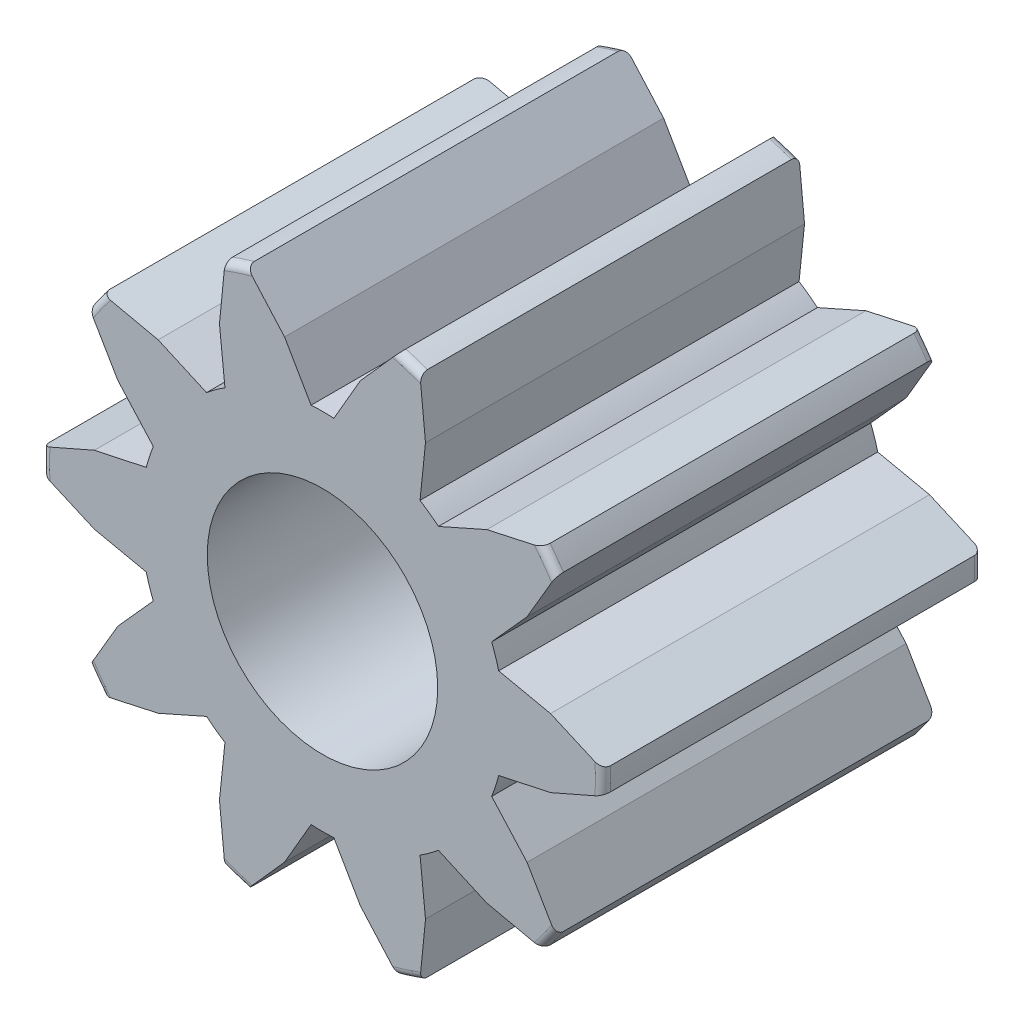
from build123d import *

# Parameters (mm, degrees)
CROQUIS1_R              = 1.85
SALIENTE_EXTRUIR1_DEPTH = 2.5
CORTAR_EXTRUIR1_DEPTH   = 2.85
REDONDEO1_R             = 0.05
MATRIZC1_COUNT          = 10
CROQUIS2_3_R            = 0.76
CORTAR_EXTRUIR2_DEPTH   = 2.85


with BuildPart() as part:
    # Croquis1 → Saliente-Extruir1 (new body)
    with BuildSketch(Plane.XY):
        Circle(CROQUIS1_R)
    extrude(amount=SALIENTE_EXTRUIR1_DEPTH)

    # Croquis2 → Cortar-Extruir1 (cut)
    with BuildSketch(Plane.XY.offset(2.5)):
        with BuildLine():
            Line((0.5, 1.781151313), (0.5, 2.25))
            Line((0.5, 2.25), (-0.5, 2.25))
            Line((-0.5, 2.25), (-0.5, 1.781151313))
            Line((-0.5, 1.781151313), (-0.25, 1.5))
            Line((-0.25, 1.5), (-0.075, 1.197653957))
            ThreePointArc((-0.075, 1.197653957), (0, 1.2), (0.075, 1.197653957))
            Line((0.075, 1.197653957), (0.25, 1.5))
            Line((0.25, 1.5), (0.5, 1.781151313))
        make_face()
    cortar_extruir1 = extrude(amount=-CORTAR_EXTRUIR1_DEPTH, mode=Mode.SUBTRACT)

    # Redondeo1
    redondeo1_edges = [part.edges().sort_by_distance(p)[0] for p in [
        (0, -1.85, 0),
        (0, -1.85, 2.5),
    ]]
    fillet(redondeo1_edges, radius=REDONDEO1_R)

    # MatrizC1: Cortar-Extruir1 ×10 about axis
    matrizc1_axis = Axis((0, 0, 0), (0, 0, 1))
    for i in range(1, MATRIZC1_COUNT):
        add(cortar_extruir1.rotate(matrizc1_axis, i * 360 / MATRIZC1_COUNT), mode=Mode.SUBTRACT)

    # Croquis2_3 → Cortar-Extruir2 (cut)
    with BuildSketch(Plane.XY.offset(2.5)):
        Circle(CROQUIS2_3_R)
    extrude(amount=-CORTAR_EXTRUIR2_DEPTH, mode=Mode.SUBTRACT)


solid = part.part
